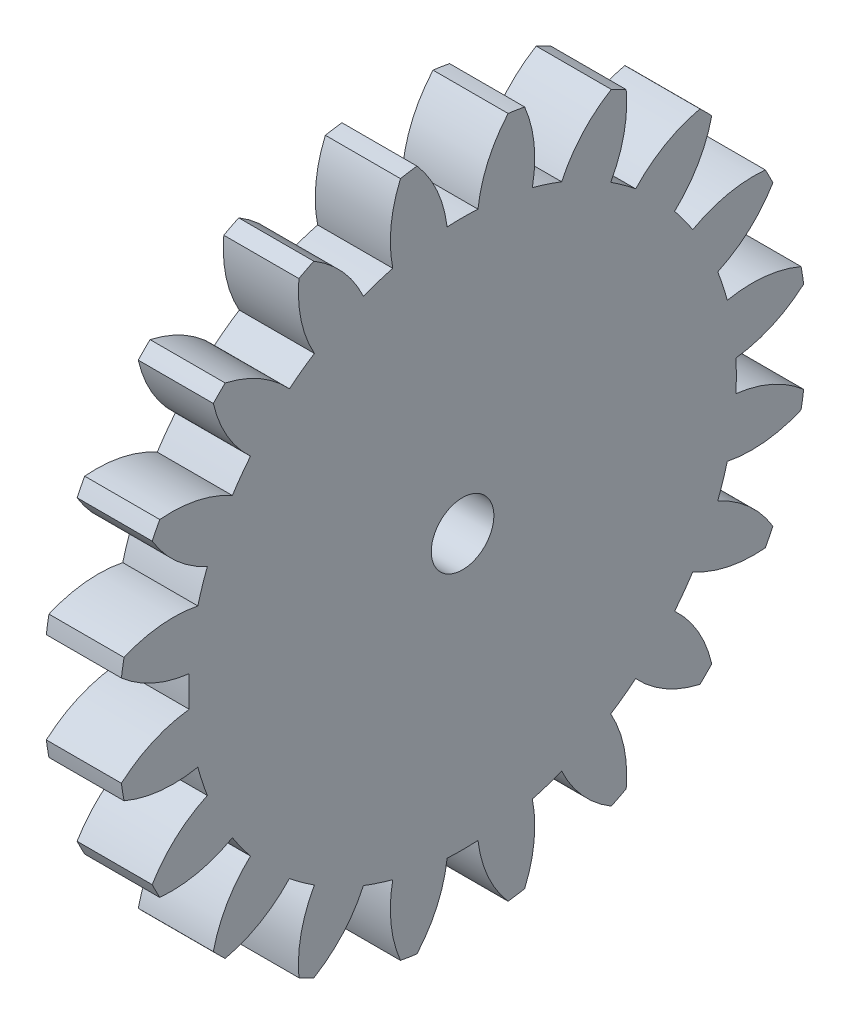
from build123d import *

# Parameters (mm, degrees)
BASPROSKE_W     = 12
BASPROSKE_H     = 55
TOOTHCUT_DEPTH  = 79.70196948
TEETHCUTS_COUNT = 20
TEETHCUTS_ANGLE = 342
BORSKE_R        = 5
BORE_DEPTH      = 50.0000508


with BuildPart() as part:
    # BasProSke → Base-Revolve (revolve)
    with BuildSketch(Plane(origin=(0, 0, 0), x_dir=(1, 0, 0), z_dir=(0, 1, 0)), mode=Mode.PRIVATE) as base_revolve_sk:
        with Locations((6, 27.5)):
            Rectangle(BASPROSKE_W, BASPROSKE_H)
    revolve(base_revolve_sk.sketch.rotate(Axis((-10, 0, 0), (1, 0, 0)), 180), axis=Axis((-10, 0, 0), (1, 0, 0)))

    # TooCutSke → ToothCut (cut, through all)
    with BuildSketch(Plane(origin=(0, 0, 0), x_dir=(0, 0, -1), z_dir=(1, 0, 0))):
        with BuildLine():
            ThreePointArc((2.464838288, 43.679509764), (0, 43.749), (-2.464838288, 43.679509764))
            ThreePointArc((-2.464838288, 43.679509764), (-4.057398861, 49.476814676), (-7.300899231, 54.538899105))
            ThreePointArc((-7.300899231, 54.538899105), (0, 55.0254), (7.300899231, 54.538899105))
            ThreePointArc((7.300899231, 54.538899105), (4.057398861, 49.476814676), (2.464838288, 43.679509764))
        make_face()
    toothcut = extrude(amount=TOOTHCUT_DEPTH, mode=Mode.SUBTRACT)

    # TeethCuts: ToothCut ×20 about axis
    teethcuts_axis = Axis((-10, 0, 0), (1, 0, 0))
    for i in range(1, TEETHCUTS_COUNT):
        add(toothcut.rotate(teethcuts_axis, i * TEETHCUTS_ANGLE / (TEETHCUTS_COUNT - 1)), mode=Mode.SUBTRACT)

    # BorSke → Bore (cut, symmetric)
    with BuildSketch(Plane(origin=(0, 0, 0), x_dir=(0, 0, -1), z_dir=(1, 0, 0))):
        with Locations(Location((0, 0, 0), (0, 0, 180))):
            Circle(BORSKE_R)
    extrude(amount=BORE_DEPTH, both=True, mode=Mode.SUBTRACT)


solid = part.part
